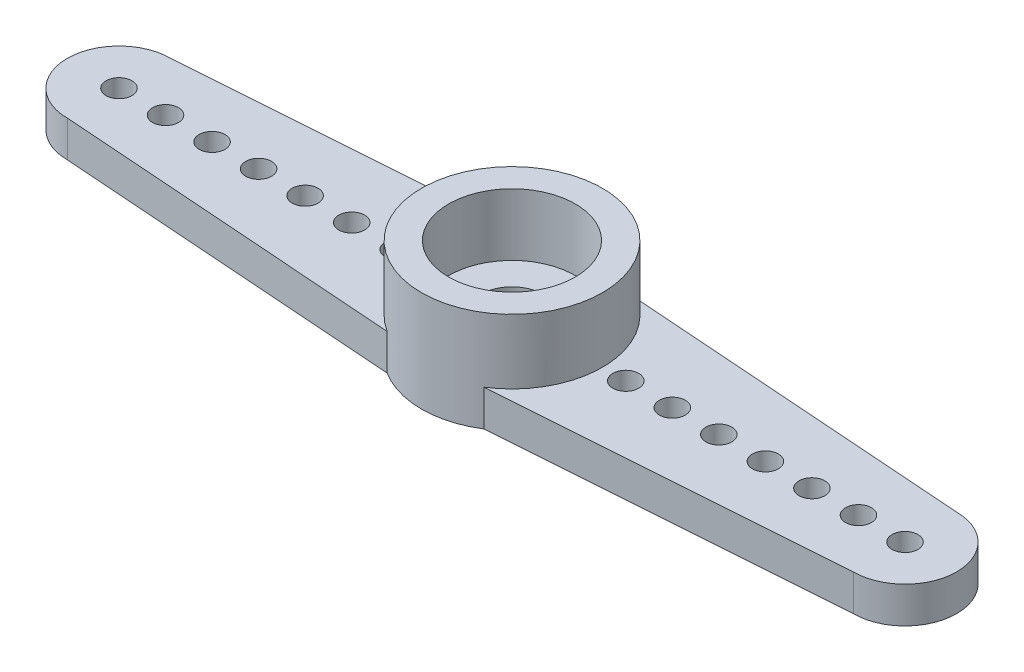
from build123d import *

# Parameters (mm, degrees)
SKETCH1_R           = 0.5
BOSS_EXTRUDE1_DEPTH = 1.4
SKETCH2_R           = 2.35
CUT_EXTRUDE1_DEPTH  = 1
SKETCH3_R           = 3.5
SKETCH3_R_2         = 2.45
BOSS_EXTRUDE2_DEPTH = 2.5
SKETCH4_R           = 1.2
CUT_EXTRUDE2_DEPTH  = 2.4
SKETCH5_R           = 2.45
SKETCH5_R_2         = 1.2
BOSS_EXTRUDE3_DEPTH = 0.1
SKETCH6_W           = 35.735260114
SKETCH6_H           = 17.672039004
CUT_EXTRUDE4_DEPTH  = 4.9


with BuildPart() as part:
    # Sketch1 → Boss-Extrude1 (new body)
    with BuildSketch(Plane(origin=(0, 0, 0), x_dir=(1, 0, 0), z_dir=(0, 1, 0))):
        with BuildLine():
            Line((-15.2, 2), (-2, 2.95))
            Line((-2, 2.95), (-2, 6.35))
            ThreePointArc((-2, 6.35), (0, 8.35), (2, 6.35))
            Line((2, 6.35), (2, 3.5))
            Line((2, 3.5), (15.2, 2))
            ThreePointArc((15.2, 2), (17.2, 0), (15.2, -2))
            Line((15.2, -2), (2, -3.5))
            Line((2, -3.5), (2, -6.35))
            ThreePointArc((2, -6.35), (0, -8.35), (-2, -6.35))
            Line((-2, -6.35), (-2, -2.95))
            Line((-2, -2.95), (-15.2, -2))
            ThreePointArc((-15.2, -2), (-17.2, 0), (-15.2, 2))
        make_face()
        with Locations((0, 6.35)):
            Circle(SKETCH1_R, mode=Mode.SUBTRACT)
        with Locations((0, 4.55)):
            Circle(SKETCH1_R, mode=Mode.SUBTRACT)
        with Locations((0, -4.55)):
            Circle(SKETCH1_R, mode=Mode.SUBTRACT)
        with Locations((0, -6.35)):
            Circle(SKETCH1_R, mode=Mode.SUBTRACT)
        with Locations((-15.2, 0)):
            Circle(SKETCH1_R, mode=Mode.SUBTRACT)
        with Locations((15.2, 0)):
            Circle(SKETCH1_R, mode=Mode.SUBTRACT)
        with Locations((-13.4, 0)):
            Circle(SKETCH1_R, mode=Mode.SUBTRACT)
        with Locations((-11.6, 0)):
            Circle(SKETCH1_R, mode=Mode.SUBTRACT)
        with Locations((-9.8, 0)):
            Circle(SKETCH1_R, mode=Mode.SUBTRACT)
        with Locations((-8, 0)):
            Circle(SKETCH1_R, mode=Mode.SUBTRACT)
        with Locations((-6.2, 0)):
            Circle(SKETCH1_R, mode=Mode.SUBTRACT)
        with Locations((-4.4, 0)):
            Circle(SKETCH1_R, mode=Mode.SUBTRACT)
        with Locations((13.4, 0)):
            Circle(SKETCH1_R, mode=Mode.SUBTRACT)
        with Locations((11.6, 0)):
            Circle(SKETCH1_R, mode=Mode.SUBTRACT)
        with Locations((9.8, 0)):
            Circle(SKETCH1_R, mode=Mode.SUBTRACT)
        with Locations((8, 0)):
            Circle(SKETCH1_R, mode=Mode.SUBTRACT)
        with Locations((6.2, 0)):
            Circle(SKETCH1_R, mode=Mode.SUBTRACT)
        with Locations((4.4, 0)):
            Circle(SKETCH1_R, mode=Mode.SUBTRACT)
    extrude(amount=BOSS_EXTRUDE1_DEPTH)

    # Sketch2 → Cut-Extrude1 (cut)
    with BuildSketch(Plane.XZ):
        Circle(SKETCH2_R)
    extrude(amount=-CUT_EXTRUDE1_DEPTH, mode=Mode.SUBTRACT)

    # Sketch3 → Boss-Extrude2 (add)
    with BuildSketch(Plane(origin=(0, 1.4, 0), x_dir=(1, 0, 0), z_dir=(0, 1, 0))):
        Circle(SKETCH3_R)
        Circle(SKETCH3_R_2, mode=Mode.SUBTRACT)
    extrude(amount=BOSS_EXTRUDE2_DEPTH)

    # Sketch4 → Cut-Extrude2 (cut, through all)
    with BuildSketch(Plane(origin=(0, 1.4, 0), x_dir=(1, 0, 0), z_dir=(0, 1, 0))):
        Circle(SKETCH4_R)
    extrude(amount=-CUT_EXTRUDE2_DEPTH, mode=Mode.SUBTRACT)

    # Sketch5 → Boss-Extrude3 (add)
    with BuildSketch(Plane(origin=(0, 1.4, 0), x_dir=(1, 0, 0), z_dir=(0, 1, 0))):
        Circle(SKETCH5_R)
        Circle(SKETCH5_R_2, mode=Mode.SUBTRACT)
    extrude(amount=BOSS_EXTRUDE3_DEPTH)

    # Sketch6 → Cut-Extrude4 (cut, through all)
    with BuildSketch(Plane.XZ):
        Rectangle(SKETCH6_W, SKETCH6_H)
        with BuildLine():
            Line((-1.868584713, -2.959457918), (-15.2, -2))
            ThreePointArc((-15.2, -2), (-17.2, 0), (-15.2, 2))
            Line((-15.2, 2), (-1.868584713, 2.959457918))
            ThreePointArc((-1.868584713, 2.959457918), (0, 3.5), (1.868584713, 2.959457918))
            Line((1.868584713, 2.959457918), (15.2, 2))
            ThreePointArc((15.2, 2), (17.2, 0), (15.2, -2))
            Line((15.2, -2), (1.868584713, -2.959457918))
            ThreePointArc((1.868584713, -2.959457918), (0, -3.5), (-1.868584713, -2.959457918))
        make_face(mode=Mode.SUBTRACT)
    extrude(amount=-CUT_EXTRUDE4_DEPTH, mode=Mode.SUBTRACT)


solid = part.part
